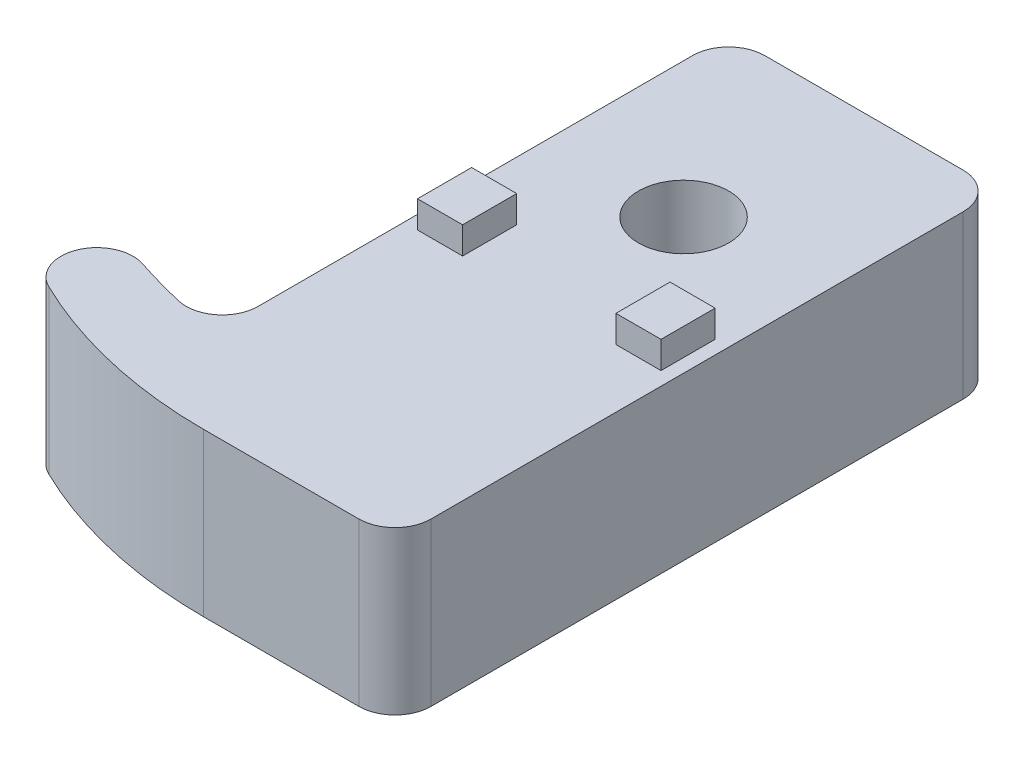
from build123d import *

# Parameters (mm, degrees)
SKETCH_1_R          = 2.5
EXTRUDE_1_DEPTH     = 9
SKETCH_3_W          = 2.5
SKETCH_3_H          = 3
EXTRUDE_2_DEPTH     = 1.5
CUT_EXTRUDE_1_REACH = 11
SKETCH_5_W          = 13
SKETCH_5_H          = 1.5
SKETCH_6_W          = 13
SKETCH_6_H          = 1.5
EXTRUDE_3_DEPTH     = 1
CUT_EXTRUDE_2_REACH = 35.5
SKETCH_7_W          = 13
SKETCH_7_H          = 1


with BuildPart() as part:
    # 草图1 → 凸台-拉伸1 (new body)
    with BuildSketch(Plane(origin=(0, 0, 0), x_dir=(1, 0, 0), z_dir=(0, 1, 0))):
        with BuildLine():
            Line((-2.382835885, 33.5), (8.617164115, 33.5))
            ThreePointArc((8.617164115, 33.5), (10.031377677, 32.914213562), (10.617164115, 31.5))
            Line((10.617164115, 31.5), (10.617164115, 2))
            ThreePointArc((10.617164115, 2), (10.031377677, 0.585786438), (8.617164115, 0))
            Line((8.617164115, 0), (0, 0))
            ThreePointArc((0, 0), (-5.710600422, 0.647655185), (-11.131122415, 2.557722132))
            ThreePointArc((-11.131122415, 2.557722132), (-12.111898361, 5.107720531), (-9.633282348, 6.257014206))
            ThreePointArc((-9.633282348, 6.257014206), (-8.243555708, 5.833986106), (-6.836394497, 5.473167269))
            ThreePointArc((-6.836394497, 5.473167269), (-5.139275919, 5.854675685), (-4.382835885, 7.421059613))
            Line((-4.382835885, 7.421059613), (-4.382835885, 31.5))
            ThreePointArc((-4.382835885, 31.5), (-3.797049447, 32.914213562), (-2.382835885, 33.5))
        make_face()
        with Locations((3.117164115, 23.5)):
            Circle(SKETCH_1_R, mode=Mode.SUBTRACT)
    extrude(amount=EXTRUDE_1_DEPTH)

    # 草图3 → 凸台-拉伸2 (add)
    with BuildSketch(Plane(origin=(0, 9, 0), x_dir=(1, 0, 0), z_dir=(0, 1, 0))):
        with Locations((-2.382835885, 17)):
            Rectangle(SKETCH_3_W, SKETCH_3_H)
        with Locations((8.617164115, 17)):
            Rectangle(SKETCH_3_W, SKETCH_3_H)
    extrude(amount=EXTRUDE_2_DEPTH)

    # 草图5 → 切除-拉伸1 (cut, up to next)
    with BuildSketch(Plane(origin=(0, 9, 0), x_dir=(1, 0, 0), z_dir=(0, 1, 0)), mode=Mode.PRIVATE) as cut_extrude_1_sk1:
        with Locations((2.117164115, 30.75)):
            Rectangle(SKETCH_5_W, SKETCH_5_H)
    cut_extrude_1_tool1 = extrude(cut_extrude_1_sk1.sketch, amount=-CUT_EXTRUDE_1_REACH, mode=Mode.PRIVATE) & part.part
    add(cut_extrude_1_tool1.solids().sort_by_distance((2.117164, 9, -30.75))[0], mode=Mode.SUBTRACT)

    # 草图6 → 凸台-拉伸3 (add)
    with BuildSketch(Plane(origin=(0, 9, 0), x_dir=(1, 0, 0), z_dir=(0, 1, 0))):
        with Locations((2.117164115, 30.75)):
            Rectangle(SKETCH_6_W, SKETCH_6_H)
    extrude(amount=-EXTRUDE_3_DEPTH)

    # 草图7 → 切除-拉伸2 (cut, up to next)
    with BuildSketch(Plane(origin=(0, 0, -33.5), x_dir=(-1, 0, 0), z_dir=(0, 0, -1)), mode=Mode.PRIVATE) as cut_extrude_2_sk1:
        with Locations((-2.117164115, 2)):
            Rectangle(SKETCH_7_W, SKETCH_7_H)
    cut_extrude_2_tool1 = extrude(cut_extrude_2_sk1.sketch, amount=-CUT_EXTRUDE_2_REACH, mode=Mode.PRIVATE) & part.part
    add(cut_extrude_2_tool1.solids().sort_by_distance((2.117164, 2, -33.5))[0], mode=Mode.SUBTRACT)


solid = part.part
